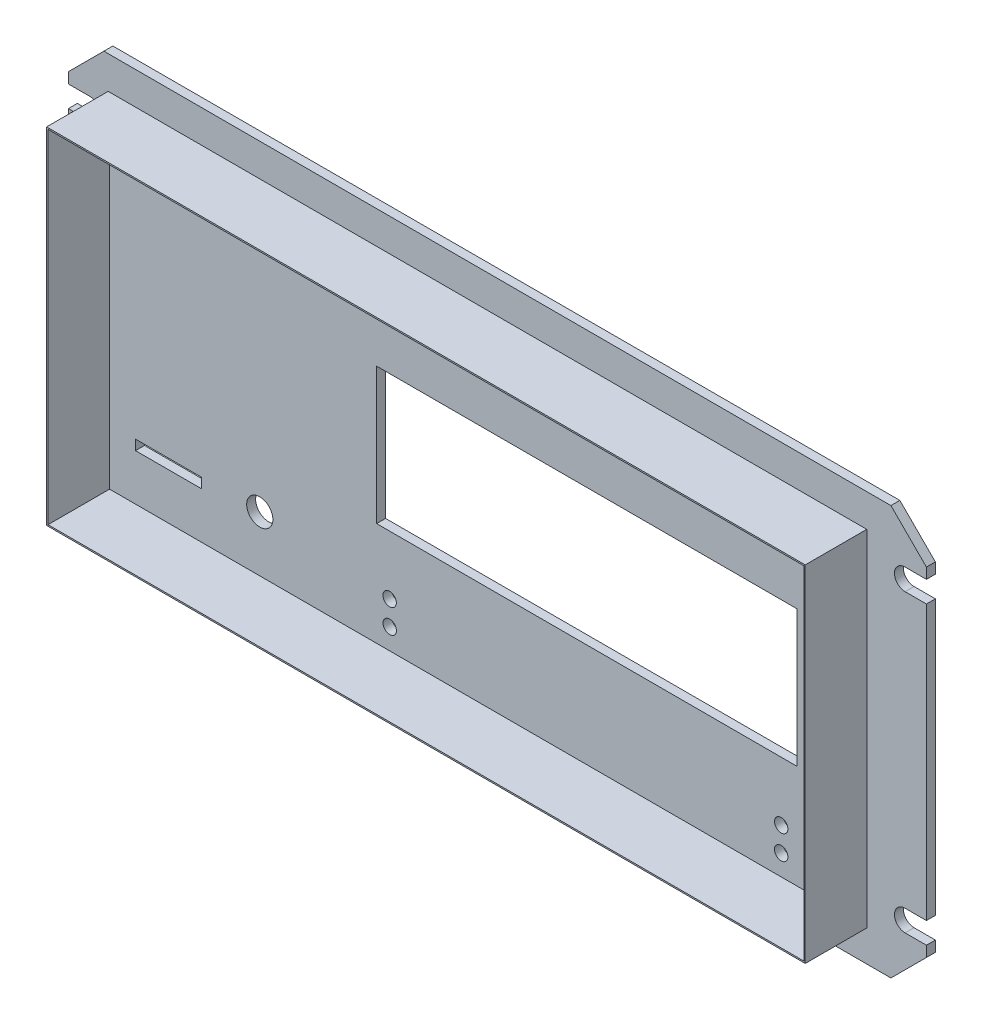
from build123d import *

# Parameters (mm, degrees)
BOSS_EXTRUDE1_DEPTH      = 1.6002
CUT_EXTRUDE1_DEPTH       = 2.6002
CUT_EXTRUDE2_DEPTH       = 2.6002
CUT_EXTRUDE3_DEPTH       = 2.6002
CUT_EXTRUDE4_DEPTH       = 2.6002
SKETCH6_W                = 135.636
SKETCH6_H                = 61.722
BOSS_EXTRUDE2_DEPTH      = 11
SKETCH7_W                = 135.128
SKETCH7_H                = 61.214
CUT_EXTRUDE5_DEPTH       = 11
SKETCH8_W                = 75.184
SKETCH8_H                = 24.384
CUT_EXTRUDE6_DEPTH       = 2.6002
SKETCH9_W                = 11.792676588
SKETCH9_H                = 1.790289347
CUT_EXTRUDE7_DEPTH       = 13.6002
M2_CLEARANCE_HOLE1_D     = 2.39776
M2_CLEARANCE_HOLE1_DEPTH = 1.6002
M4_CLEARANCE_HOLE2_D     = 4.68589235
M4_CLEARANCE_HOLE2_DEPTH = 1.6002


with BuildPart() as part:
    # Sketch1 → Boss-Extrude1 (new body)
    with BuildSketch(Plane.XY.offset(1.6002)):
        Polygon((6.35, 70.612), (0, 64.262), (0, 3.81), (6.35, -2.54), (147.066, -2.54), (153.416, 3.81), (153.416, 64.262), (147.066, 70.612), align=None)
    extrude(amount=-BOSS_EXTRUDE1_DEPTH)

    # Sketch2 → Cut-Extrude1 (cut, through all)
    with BuildSketch(Plane(origin=(0, 0, 0), x_dir=(-1, 0, 0), z_dir=(0, 0, -1))):
        with BuildLine():
            Line((-153.416, 9.525), (-153.416, 5.715))
            Line((-153.416, 5.715), (-149.606, 5.715))
            ThreePointArc((-149.606, 5.715), (-147.701, 7.62), (-149.606, 9.525))
            Line((-149.606, 9.525), (-153.416, 9.525))
        make_face()
    extrude(amount=-CUT_EXTRUDE1_DEPTH, mode=Mode.SUBTRACT)

    # Sketch3 → Cut-Extrude2 (cut, through all)
    with BuildSketch(Plane(origin=(0, 0, 0), x_dir=(-1, 0, 0), z_dir=(0, 0, -1))):
        with BuildLine():
            Line((-153.416, 62.357), (-153.416, 58.547))
            Line((-153.416, 58.547), (-149.606, 58.547))
            ThreePointArc((-149.606, 58.547), (-147.701, 60.452), (-149.606, 62.357))
            Line((-149.606, 62.357), (-153.416, 62.357))
        make_face()
    extrude(amount=-CUT_EXTRUDE2_DEPTH, mode=Mode.SUBTRACT)

    # Sketch4 → Cut-Extrude3 (cut, through all)
    with BuildSketch(Plane(origin=(0, 0, 0), x_dir=(-1, 0, 0), z_dir=(0, 0, -1))):
        with BuildLine():
            Line((0, 58.547), (0, 62.357))
            Line((0, 62.357), (-3.81, 62.357))
            ThreePointArc((-3.81, 62.357), (-5.715, 60.452), (-3.81, 58.547))
            Line((-3.81, 58.547), (0, 58.547))
        make_face()
    extrude(amount=-CUT_EXTRUDE3_DEPTH, mode=Mode.SUBTRACT)

    # Sketch5 → Cut-Extrude4 (cut, through all)
    with BuildSketch(Plane(origin=(0, 0, 0), x_dir=(-1, 0, 0), z_dir=(0, 0, -1))):
        with BuildLine():
            Line((0, 5.715), (0, 9.525))
            Line((0, 9.525), (-3.81, 9.525))
            ThreePointArc((-3.81, 9.525), (-5.715, 7.62), (-3.81, 5.715))
            Line((-3.81, 5.715), (0, 5.715))
        make_face()
    extrude(amount=-CUT_EXTRUDE4_DEPTH, mode=Mode.SUBTRACT)

    # Sketch6 → Boss-Extrude2 (add)
    with BuildSketch(Plane.XY.offset(1.6002)):
        with Locations((74.93, 33.909)):
            Rectangle(SKETCH6_W, SKETCH6_H)
    extrude(amount=BOSS_EXTRUDE2_DEPTH)

    # Sketch7 → Cut-Extrude5 (cut)
    with BuildSketch(Plane.XY.offset(12.6002)):
        with Locations((74.93, 33.909)):
            Rectangle(SKETCH7_W, SKETCH7_H)
    extrude(amount=-CUT_EXTRUDE5_DEPTH, mode=Mode.SUBTRACT)

    # Sketch8 → Cut-Extrude6 (cut, through all)
    with BuildSketch(Plane.XY.offset(1.6002)):
        with Locations((92.71, 34.036)):
            Rectangle(SKETCH8_W, SKETCH8_H)
    extrude(amount=-CUT_EXTRUDE6_DEPTH, mode=Mode.SUBTRACT)

    # Sketch9 → Cut-Extrude7 (cut, through all)
    with BuildSketch(Plane(origin=(0, 0, 0), x_dir=(-1, 0, 0), z_dir=(0, 0, -1))):
        with Locations((-17.905053156, 12.47860787)):
            Rectangle(SKETCH9_W, SKETCH9_H)
    extrude(amount=-CUT_EXTRUDE7_DEPTH, mode=Mode.SUBTRACT)

    # M2 Clearance Hole1
    with Locations(Plane.XY.offset(1.6002)):
        with Locations((127.4445, 6.98246), (127.44958, 11.303), (57.4548, 7.03326), (57.43956, 11.32332)):
            Hole(M2_CLEARANCE_HOLE1_D / 2, depth=M2_CLEARANCE_HOLE1_DEPTH)

    # M4 Clearance Hole2
    with Locations(Plane.XY.offset(1.6002)):
        with Locations((34.22065157, 13.205568935)):
            Hole(M4_CLEARANCE_HOLE2_D / 2, depth=M4_CLEARANCE_HOLE2_DEPTH)


solid = part.part
